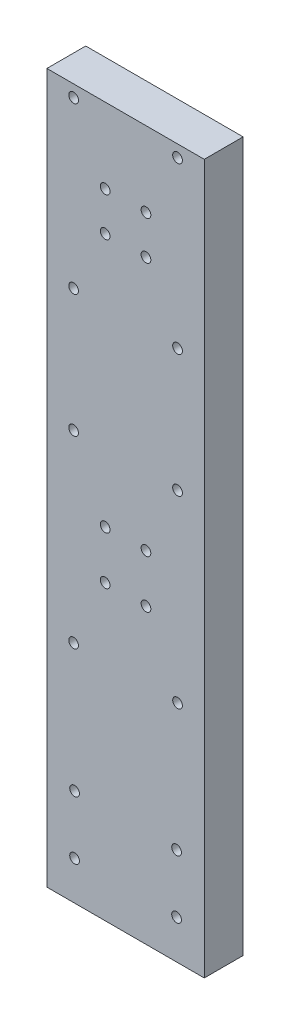
from build123d import *

# Parameters (mm, degrees)
SKETCH1_W           = 16.2
SKETCH1_H           = 72.99
SKETCH1_R           = 0.5
BOSS_EXTRUDE1_DEPTH = 4


with BuildPart() as part:
    # Sketch1 → Boss-Extrude1 (new body)
    with BuildSketch(Plane.XY):
        with Locations((8.1, 36.495)):
            Rectangle(SKETCH1_W, SKETCH1_H)
        with Locations((6, 30.15)):
            Circle(SKETCH1_R, mode=Mode.SUBTRACT)
        with Locations((10.2, 30.15)):
            Circle(SKETCH1_R, mode=Mode.SUBTRACT)
        with Locations((10.2, 35.11)):
            Circle(SKETCH1_R, mode=Mode.SUBTRACT)
        with Locations((10.2, 61.26)):
            Circle(SKETCH1_R, mode=Mode.SUBTRACT)
        with Locations((13.45, 54.76)):
            Circle(SKETCH1_R, mode=Mode.SUBTRACT)
        with Locations((6, 61.26)):
            Circle(SKETCH1_R, mode=Mode.SUBTRACT)
        with Locations((6, 35.11)):
            Circle(SKETCH1_R, mode=Mode.SUBTRACT)
        with Locations((2.75, 42.11)):
            Circle(SKETCH1_R, mode=Mode.SUBTRACT)
        with Locations((2.85, 10)):
            Circle(SKETCH1_R, mode=Mode.SUBTRACT)
        with Locations((13.35, 10)):
            Circle(SKETCH1_R, mode=Mode.SUBTRACT)
        with Locations((13.35, 4)):
            Circle(SKETCH1_R, mode=Mode.SUBTRACT)
        with Locations((2.85, 4)):
            Circle(SKETCH1_R, mode=Mode.SUBTRACT)
        with Locations((13.45, 42.11)):
            Circle(SKETCH1_R, mode=Mode.SUBTRACT)
        with Locations((2.75, 54.76)):
            Circle(SKETCH1_R, mode=Mode.SUBTRACT)
        with Locations((13.45, 23.15)):
            Circle(SKETCH1_R, mode=Mode.SUBTRACT)
        with Locations((2.75, 23.15)):
            Circle(SKETCH1_R, mode=Mode.SUBTRACT)
        with Locations((10.2, 65.26)):
            Circle(SKETCH1_R, mode=Mode.SUBTRACT)
        with Locations((13.45, 71.76)):
            Circle(SKETCH1_R, mode=Mode.SUBTRACT)
        with Locations((6, 65.26)):
            Circle(SKETCH1_R, mode=Mode.SUBTRACT)
        with Locations((2.75, 71.76)):
            Circle(SKETCH1_R, mode=Mode.SUBTRACT)
    extrude(amount=BOSS_EXTRUDE1_DEPTH)


solid = part.part
